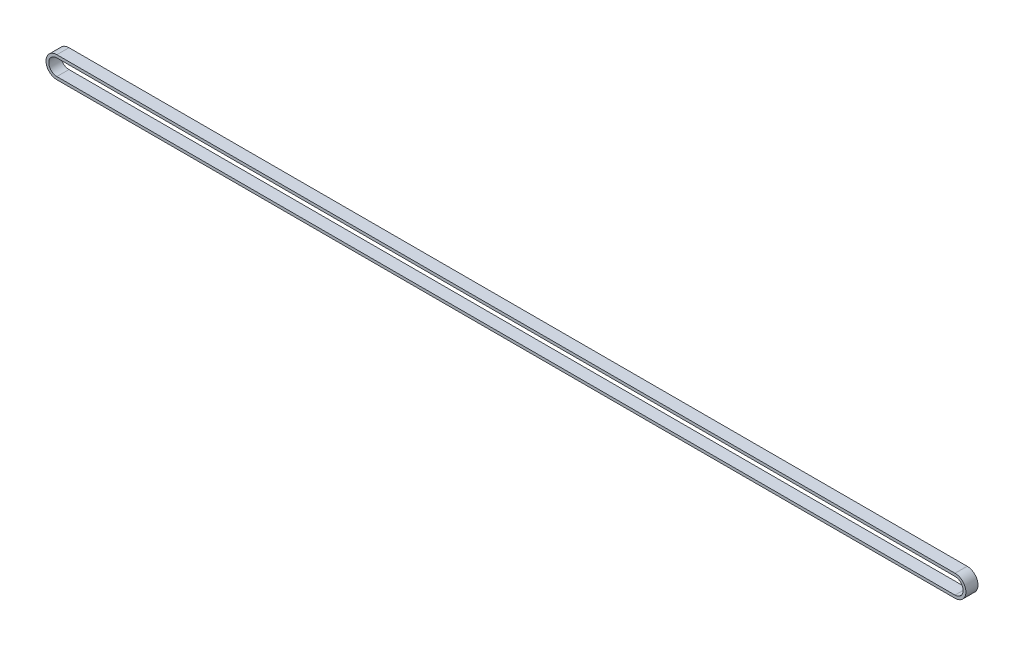
from build123d import *

# Parameters (mm, degrees)
BOSS_EXTRUDE1_DEPTH = 6


with BuildPart() as part:
    # Sketch1 → Boss-Extrude1 (new body)
    with BuildSketch(Plane.XY):
        with BuildLine():
            Line((-222.5, 5.38), (222.5, 5.38))
            ThreePointArc((222.5, 5.38), (227.88, 0), (222.5, -5.38))
            Line((222.5, -5.38), (-222.5, -5.38))
            ThreePointArc((-222.5, -5.38), (-227.88, 0), (-222.5, 5.38))
        make_face()
        with BuildLine():
            Line((-222.5, -4), (222.5, -4))
            ThreePointArc((222.5, -4), (226.5, 0), (222.5, 4))
            Line((222.5, 4), (-222.5, 4))
            ThreePointArc((-222.5, 4), (-226.5, 0), (-222.5, -4))
        make_face(mode=Mode.SUBTRACT)
    extrude(amount=BOSS_EXTRUDE1_DEPTH)


solid = part.part
